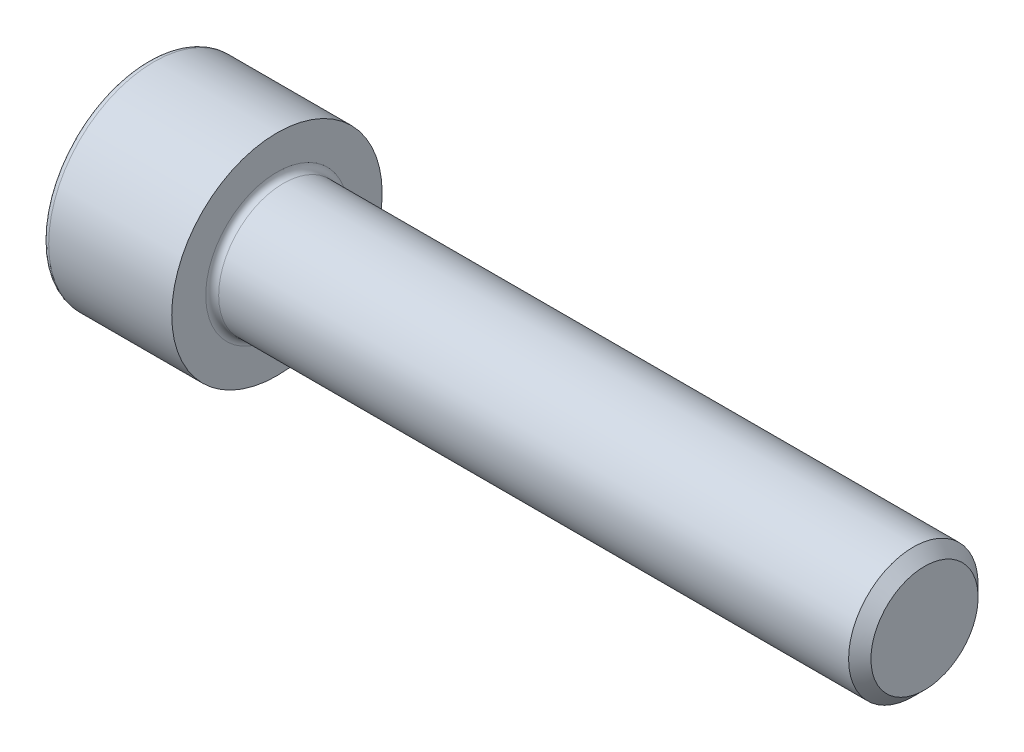
from build123d import *

# Parameters (mm, degrees)
FILLET1_R   = 0.4
FILLET2_R   = 0.4
HEX_2_DEPTH = 4


with BuildPart() as part:
    # BodySke → Base-Revolve (revolve)
    with BuildSketch(Plane.XY):
        Polygon((0, 0), (0, 6.5), (8, 6.5), (8, 4), (47.3095, 4), (48, 3.3095), (48, 0), align=None)
    revolve(axis=Axis((-31.75, 0, 0), (1, 0, 0)))

    # Fillet1
    fillet1_edges = [part.edges().sort_by_distance(p)[0] for p in [
        (8, -4, 0),
    ]]
    fillet(fillet1_edges, radius=FILLET1_R)

    # Fillet2
    fillet2_edges = [part.edges().sort_by_distance(p)[0] for p in [
        (0, -6.5, 0),
    ]]
    fillet(fillet2_edges, radius=FILLET2_R)

    # Sketch2 → Hex-PreBroach (revolve, cut)
    with BuildSketch(Plane.XY):
        Polygon((0, 3.0475), (4, 3.0475), (5.759474945, 0), (0, 0), align=None)
    revolve(axis=Axis((0, 0, 0), (1, 0, 0)), mode=Mode.SUBTRACT)

    # Sketch3 → Hex 2 (cut)
    with BuildSketch(Plane(origin=(0, 0, 0), x_dir=(0, 0.5, 0.866025404), z_dir=(-1, 0, 0))):
        Polygon((1.759474945, 3.0475), (-1.759474945, 3.0475), (-3.518949891, 0), (-1.759474945, -3.0475), (1.759474945, -3.0475), (3.518949891, 0), align=None)
    extrude(amount=-HEX_2_DEPTH, mode=Mode.SUBTRACT)


solid = part.part
